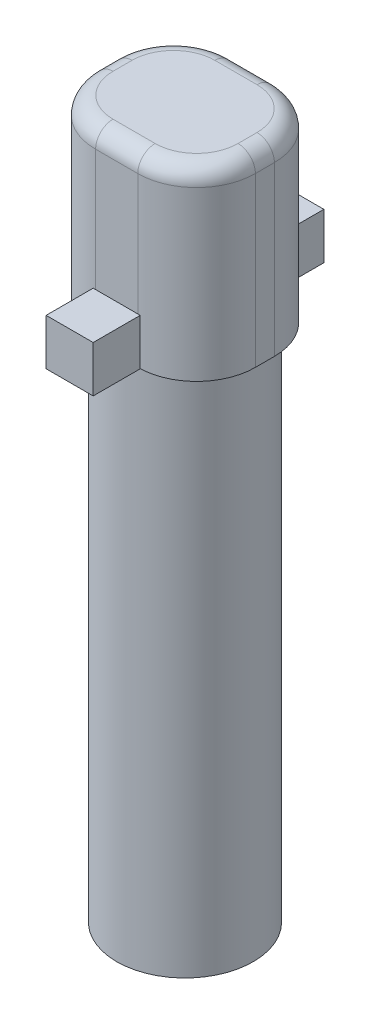
from build123d import *

# Parameters (mm, degrees)
SKETCH1_R           = 2.95
BOSS_EXTRUDE1_DEPTH = 22.686
SKETCH3_W           = 6.9
SKETCH3_H           = 5.9
BOSS_EXTRUDE2_DEPTH = 8
FILLET1_R           = 2.54
FILLET2_R           = 0.75
BOSS_EXTRUDE3_START = -8
SKETCH4_W           = 2.032
SKETCH4_H           = 2.032
BOSS_EXTRUDE3_DEPTH = 2


with BuildPart() as part:
    # Sketch1 → Boss-Extrude1 (new body)
    with BuildSketch(Plane(origin=(0, 0, 0), x_dir=(1, 0, 0), z_dir=(0, 1, 0))):
        Circle(SKETCH1_R)
    extrude(amount=BOSS_EXTRUDE1_DEPTH)

    # Sketch3 → Boss-Extrude2 (add)
    with BuildSketch(Plane(origin=(0, 22.686, 0), x_dir=(1, 0, 0), z_dir=(0, 1, 0))):
        Rectangle(SKETCH3_W, SKETCH3_H)
    extrude(amount=BOSS_EXTRUDE2_DEPTH)

    # Fillet1
    fillet1_edges = [part.edges().sort_by_distance(p)[0] for p in [
        (3.45, 26.686, 2.95),
        (3.45, 26.686, -2.95),
        (-3.45, 26.686, -2.95),
        (-3.45, 26.686, 2.95),
    ]]
    fillet(fillet1_edges, radius=FILLET1_R)

    # Fillet2
    fillet2_edges = [part.edges().sort_by_distance(p)[0] for p in [
        (-3.45, 30.686, 0),
        (0, 30.686, -2.95),
        (3.45, 30.686, 0),
        (0, 30.686, 2.95),
        (-2.706051224, 30.686, 2.206051224),
        (2.706051224, 30.686, 2.206051224),
        (2.706051224, 30.686, -2.206051224),
        (-2.706051224, 30.686, -2.206051224),
    ]]
    fillet(fillet2_edges, radius=FILLET2_R)

    # Sketch4 → Boss-Extrude3 (add)
    with BuildSketch(Plane(origin=(0, 30.686, 0), x_dir=(1, 0, 0), z_dir=(0, 1, 0)).offset(BOSS_EXTRUDE3_START)):
        with Locations((0, 3.966)):
            Rectangle(SKETCH4_W, SKETCH4_H)
        with Locations((0, -3.966)):
            Rectangle(SKETCH4_W, SKETCH4_H)
    extrude(amount=BOSS_EXTRUDE3_DEPTH)


solid = part.part
